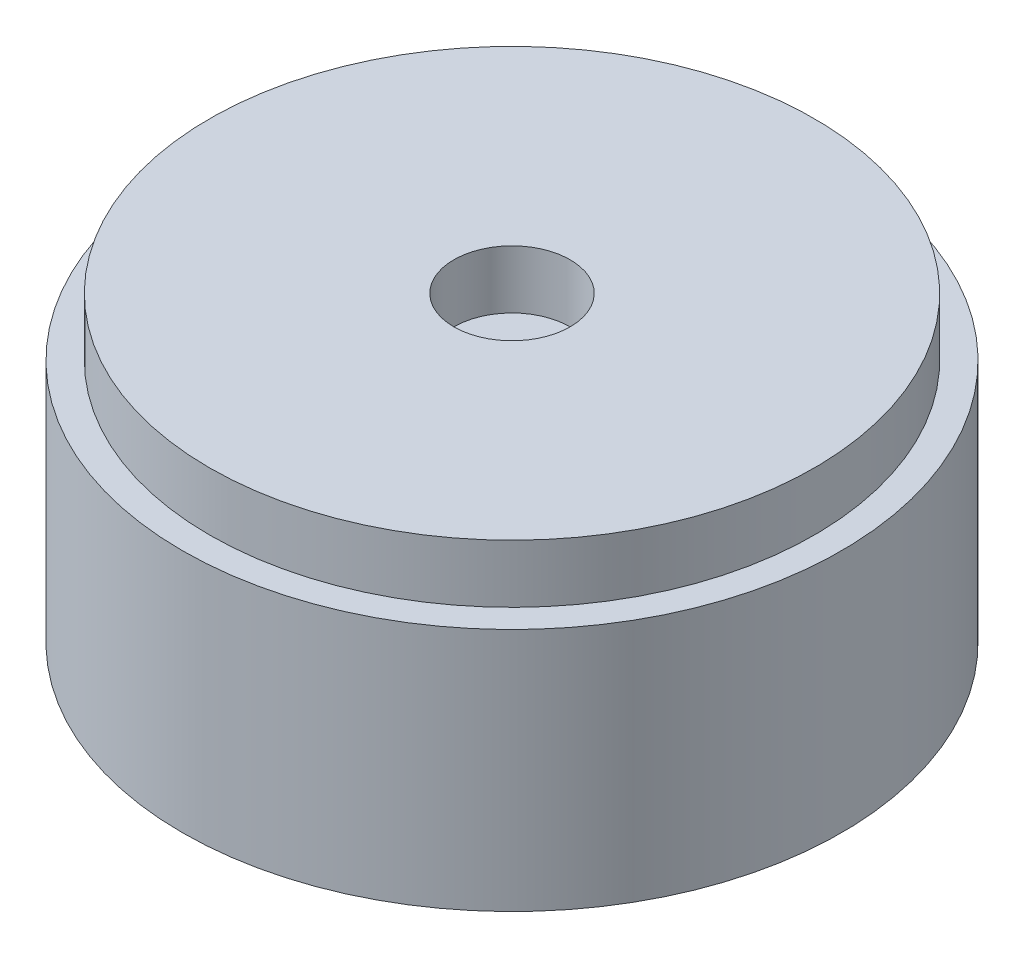
from build123d import *
from OCP.BRepFilletAPI import BRepFilletAPI_MakeChamfer

# Parameters (mm, degrees)
SKETCH1_R           = 8.5
BOSS_EXTRUDE1_DEPTH = 7.8
SKETCH2_R           = 8.5
SKETCH2_R_2         = 7.8
SKETCH2_R_3         = 1.5
CUT_EXTRUDE1_DEPTH  = 1.5
SKETCH3_R           = 0.5
BOSS_EXTRUDE2_DEPTH = 2
CHAMFER1_SIZE       = 0.5
CHAMFER1_SIZE2      = 0.1
FILLET1_R           = 1


with BuildPart() as part:
    # Sketch1 → Boss-Extrude1 (new body)
    with BuildSketch(Plane(origin=(0, 0, 0), x_dir=(1, 0, 0), z_dir=(0, 1, 0))):
        with Locations(Location((0, 0, 0), (0, 0, 270))):
            Circle(SKETCH1_R)
    extrude(amount=BOSS_EXTRUDE1_DEPTH)

    # Sketch2 → Cut-Extrude1 (cut)
    with BuildSketch(Plane(origin=(0, 7.8, 0), x_dir=(1, 0, 0), z_dir=(0, 1, 0))):
        with Locations(Location((0, 0, 0), (0, 0, 270))):
            Circle(SKETCH2_R)
        with Locations(Location((0, 0, 0), (0, 0, 270))):
            Circle(SKETCH2_R_2, mode=Mode.SUBTRACT)
        with Locations(Location((0, 0, 0), (0, 0, 270))):
            Circle(SKETCH2_R_3)
    extrude(amount=-CUT_EXTRUDE1_DEPTH, mode=Mode.SUBTRACT)

    # Sketch3 → Boss-Extrude2 (add)
    with BuildSketch(Plane.XZ):
        with Locations(Location((-5, 5, 0), (0, 0, 90))):
            Circle(SKETCH3_R)
        with Locations(Location((5, -5, 0), (0, 0, 90))):
            Circle(SKETCH3_R)
    extrude(amount=BOSS_EXTRUDE2_DEPTH)

    # Chamfer1: one chamfer whose edges measure the first distance from different faces: ONE call of the kernel's chamfer builder (chamfer() names one face for all edges)
    chamfer1_edges_1 = [part.edges().sort_by_distance(p)[0] for p in [
        (-5, -2, 4.5),
    ]]
    chamfer1_side_1 = [part.faces().sort_by_distance(p)[0] for p in [
        (-5, -1, 4.5),
    ]]
    chamfer1_edges_2 = [part.edges().sort_by_distance(p)[0] for p in [
        (5, -2, -5.5),
    ]]
    chamfer1_side_2 = [part.faces().sort_by_distance(p)[0] for p in [
        (5, -1, -5.5),
    ]]
    chamfer1 = BRepFilletAPI_MakeChamfer(part.part.solid().wrapped)
    for e in chamfer1_edges_1:
        chamfer1.Add(CHAMFER1_SIZE, CHAMFER1_SIZE2, e.wrapped, chamfer1_side_1[0].wrapped)  # the first distance lies on this face
    for e in chamfer1_edges_2:
        chamfer1.Add(CHAMFER1_SIZE, CHAMFER1_SIZE2, e.wrapped, chamfer1_side_2[0].wrapped)  # the first distance lies on this face
    add(Compound.cast(chamfer1.Shape()), mode=Mode.REPLACE)

    # Fillet1
    fillet1_edges = [part.edges().sort_by_distance(p)[0] for p in [
        (-5, -1.5, 4.5),
        (5, -1.5, -5.5),
    ]]
    fillet(fillet1_edges, radius=FILLET1_R)


solid = part.part
